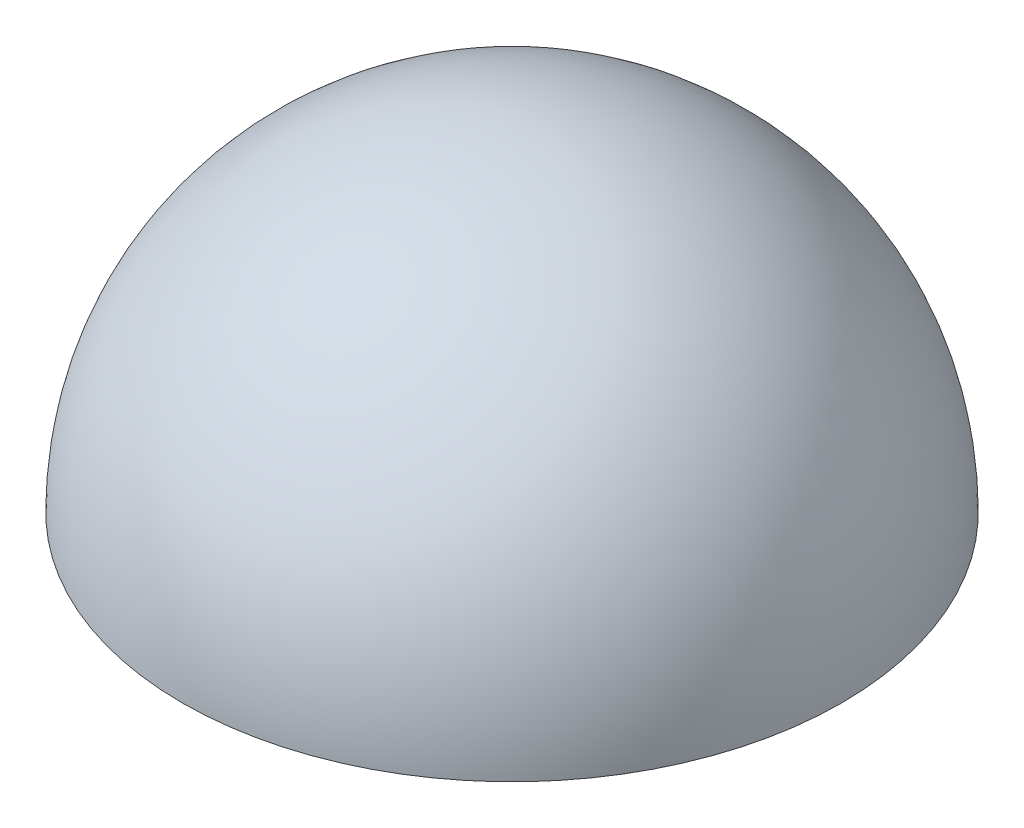
from build123d import *


with BuildPart() as part:
    # Sketch1 → Revolve2 (revolve)
    with BuildSketch(Plane.XY):
        with BuildLine():
            Line((-11, 0), (-12.2, 0))
            ThreePointArc((-12.2, 0), (-8.62670273, 8.62670273), (0, 12.2))
            Line((0, 12.2), (0, 11))
            ThreePointArc((0, 11), (-7.778174593, 7.778174593), (-11, 0))
        make_face()
    revolve(axis=Axis((0, 0, 0), (0, 1, 0)))


solid = part.part
